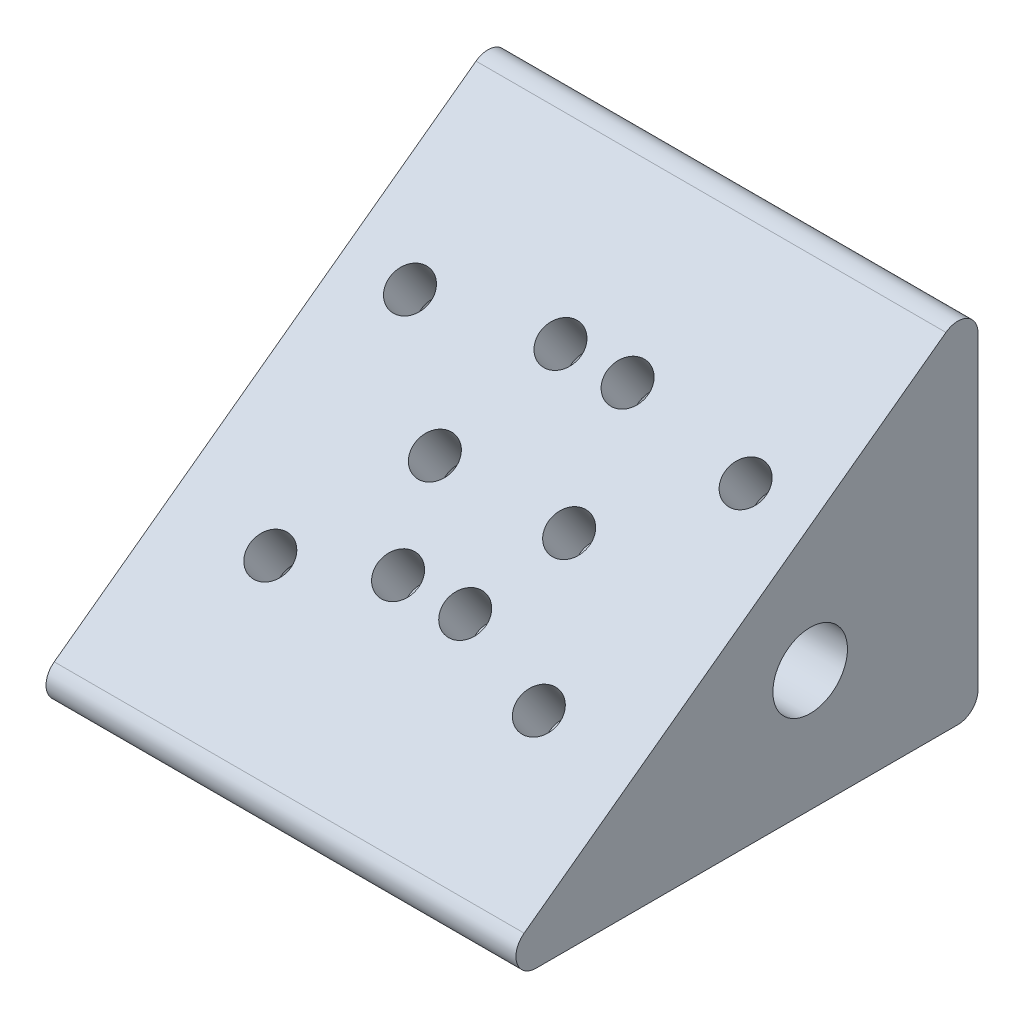
from build123d import *

# Parameters (mm, degrees)
BOSS_EXTRUDE2_DEPTH      = 35
BOSS_EXTRUDE2_DEPTH_BACK = 35
FILLET1_R                = 3
CUT_EXTRUDE1_START       = -5
CUT_EXTRUDE1_DEPTH       = 60
SKETCH6_R                = 3.0734
CUT_EXTRUDE2_DEPTH       = 8
CUT_EXTRUDE3_REACH       = 72
SKETCH7_R                = 5.55625
SKETCH8_R                = 5.55625
BOSS_EXTRUDE3_DEPTH      = 10
FILLET2_R                = 1


with BuildPart() as part:
    # Sketch3 → Boss-Extrude2 (new body, two sides)
    with BuildSketch(Plane(origin=(0, 0, 0), x_dir=(0, 0, -1), z_dir=(1, 0, 0))) as boss_extrude2_sk:
        Polygon((0, 0), (0, 55), (-75, 0), align=None)
    extrude(amount=BOSS_EXTRUDE2_DEPTH)
    extrude(boss_extrude2_sk.sketch, amount=-BOSS_EXTRUDE2_DEPTH_BACK)

    # Fillet1
    fillet1_edges = [part.edges().sort_by_distance(p)[0] for p in [
        (0, 0, 75),
        (0, 55, 0),
        (0, 0, 0),
    ]]
    fillet(fillet1_edges, radius=FILLET1_R)

    # Sketch5 → Cut-Extrude1 (cut)
    with BuildSketch(Plane(origin=(35, 0, 0), x_dir=(0, 0, -1), z_dir=(1, 0, 0)).offset(CUT_EXTRUDE1_START)):
        with BuildLine():
            Line((-4, 40.172688191), (-4, 9))
            ThreePointArc((-4, 9), (-5.464466094, 5.464466094), (-9, 4))
            Line((-9, 4), (-52.962756624, 4))
            ThreePointArc((-52.962756624, 4), (-53.913126287, 4.688877031), (-53.554120287, 5.806404996))
            Line((-53.554120287, 5.806404996), (-5.591363664, 40.979093187))
            ThreePointArc((-5.591363664, 40.979093187), (-4.547984327, 41.064698186), (-4, 40.172688191))
        make_face()
    extrude(amount=-CUT_EXTRUDE1_DEPTH, mode=Mode.SUBTRACT)

    # Sketch6 → Cut-Extrude2 (cut)
    with BuildSketch(Plane(origin=(0, 35.765895954, 26.228323699), x_dir=(1, 0, 0), z_dir=(0, 0.806404996, 0.591363664))):
        with Locations(Location((5, 5, 0), (0, 0, 270))):  # turned: the seam where the file's is
            Circle(SKETCH6_R)
        with Locations(Location((5, -25, 0), (0, 0, 270))):  # turned: the seam where the file's is
            Circle(SKETCH6_R)
        with Locations(Location((20, -30, 0), (0, 0, 270))):  # turned: the seam where the file's is
            Circle(SKETCH6_R)
        with Locations(Location((10, -12, 0), (0, 0, 270))):  # turned: the seam where the file's is
            Circle(SKETCH6_R)
        with Locations(Location((25, 2, 0), (0, 0, 270))):  # turned: the seam where the file's is
            Circle(SKETCH6_R)
    cut_extrude2 = extrude(amount=-CUT_EXTRUDE2_DEPTH, mode=Mode.SUBTRACT)

    # Mirror1: Cut-Extrude2 across plane
    add(cut_extrude2.mirror(Plane(origin=(0, 0, 0), x_dir=(0, 0, 1), z_dir=(1, 0, 0))), mode=Mode.SUBTRACT)

    # Sketch7 → Cut-Extrude3 (cut, up to next)
    with BuildSketch(Plane(origin=(35, 0, 0), x_dir=(0, 0, -1), z_dir=(1, 0, 0)), mode=Mode.PRIVATE) as cut_extrude3_sk1:
        with Locations((-25, 18)):
            Circle(SKETCH7_R)
    cut_extrude3_tool1 = extrude(cut_extrude3_sk1.sketch, amount=-CUT_EXTRUDE3_REACH, mode=Mode.PRIVATE) & part.part
    add(cut_extrude3_tool1.solids().sort_by_distance((35, 18, 25))[0], mode=Mode.SUBTRACT)

    # Sketch8 → Boss-Extrude3 (add)
    with BuildSketch(Plane(origin=(35, 0, 0), x_dir=(0, 0, -1), z_dir=(1, 0, 0))):
        with BuildLine():
            Line((-22.719584828, 28.418397666), (-35.622064762, 18.956579048))
            Line((-35.622064762, 18.956579048), (-31.451239967, 13.269090691))
            ThreePointArc((-31.451239967, 13.269090691), (-20.269090691, 11.548760033), (-18.548760033, 22.730909309))
            Line((-18.548760033, 22.730909309), (-22.719584828, 28.418397666))
        make_face()
        with Locations((-25, 18)):
            Circle(SKETCH8_R, mode=Mode.SUBTRACT)
    extrude(amount=-BOSS_EXTRUDE3_DEPTH)

    # Fillet2
    fillet2_edges = [part.edges().sort_by_distance(p)[0] for p in [
        (30, 12.381492022, 44.588092525),
        (30, 25.574653487, 20.634172431),
        (25, 25.574653487, 20.634172431),
        (30, 11.548760033, 20.269090691),
        (25, 11.548760033, 20.269090691),
        (30, 16.112834869, 33.536652364),
        (25, 16.112834869, 33.536652364),
        (30, 4.688877031, 53.913126287),
        (30, 34.698745426, 14.155474246),
        (30, 41.064698186, 4.547984327),
        (30, 24.586344095, 4),
        (30, 5.464466094, 5.464466094),
        (30, 4, 30.981378312),
        (-30, 4.688877031, 53.913126287),
        (-30, 4, 30.981378312),
        (-30, 5.464466094, 5.464466094),
        (-30, 24.586344095, 4),
        (-30, 41.064698186, 4.547984327),
        (-30, 23.392749091, 29.572741975),
    ]]
    fillet(fillet2_edges, radius=FILLET2_R)


solid = part.part
